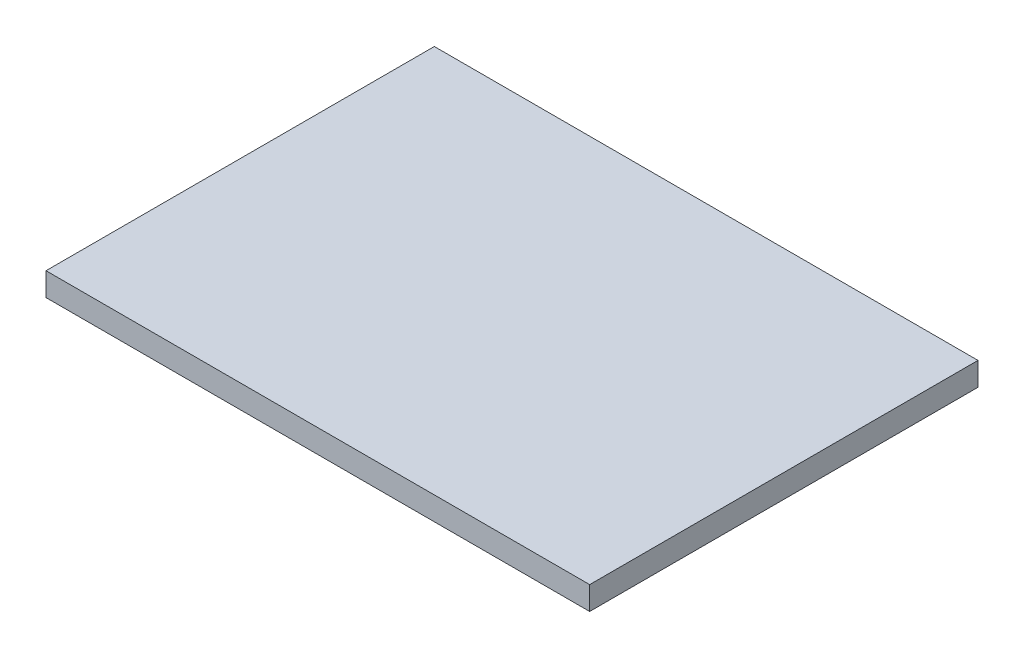
from build123d import *

# Parameters (mm, degrees)
CROQUIS1_W              = 70
CROQUIS1_H              = 50
SALIENTE_EXTRUIR1_DEPTH = 3


with BuildPart() as part:
    # Croquis1 → Saliente-Extruir1 (new body)
    with BuildSketch(Plane(origin=(0, 0, 0), x_dir=(1, 0, 0), z_dir=(0, 1, 0))):
        Rectangle(CROQUIS1_W, CROQUIS1_H)
    extrude(amount=SALIENTE_EXTRUIR1_DEPTH)


solid = part.part
